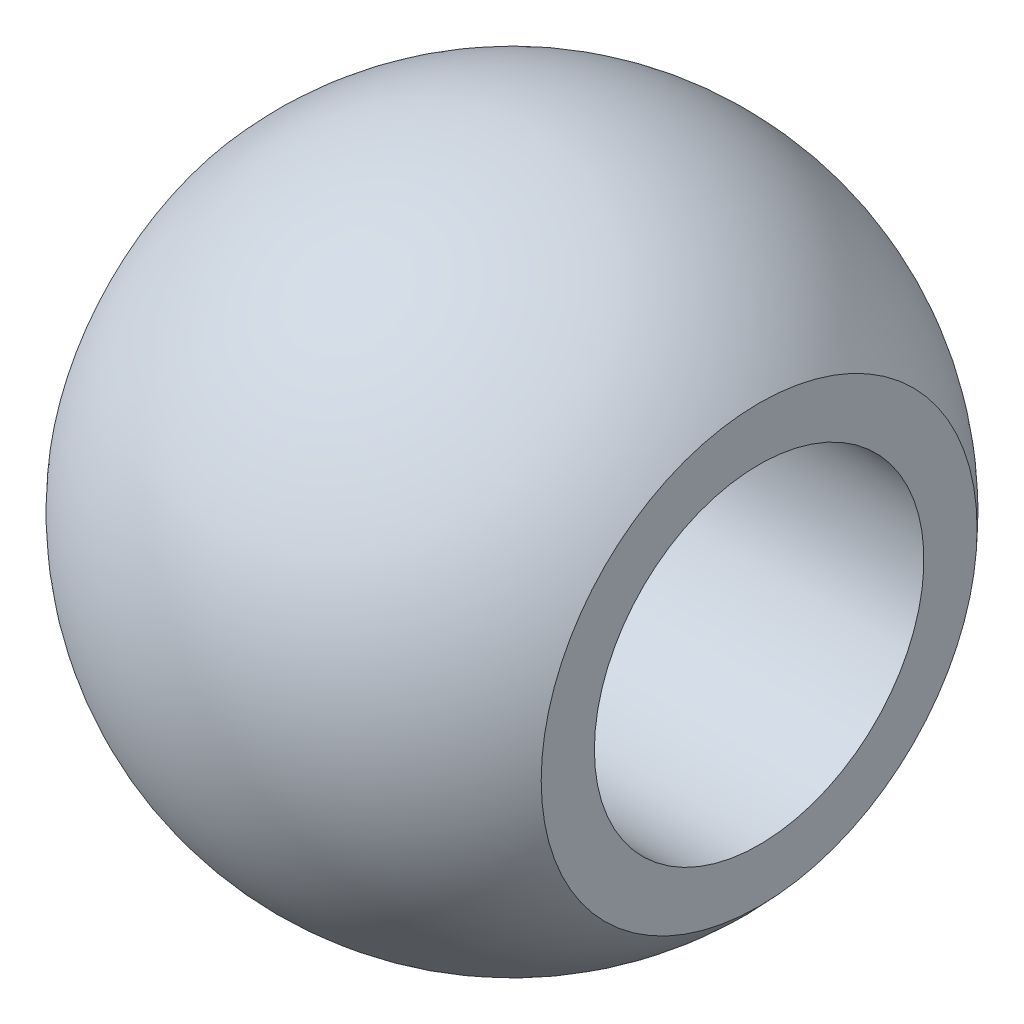
from build123d import *

# Parameters (mm, degrees)
SKETCH2_R               = 5
CUT_EXTRUDE1_DEPTH      = 1
CUT_EXTRUDE1_DEPTH_BACK = 16


with BuildPart() as part:
    # Sketch1 → Revolve1 (revolve)
    with BuildSketch(Plane.XY):
        with BuildLine():
            Line((-7.5, 0), (7.5, 0))
            Line((7.5, 0), (7.5, 6.614378278))
            ThreePointArc((7.5, 6.614378278), (0, 10), (-7.5, 6.614378278))
            Line((-7.5, 6.614378278), (-7.5, 0))
        make_face()
    revolve(axis=Axis((-10, 0, 0), (1, 0, 0)))

    # Sketch2 → Cut-Extrude1 (cut, two sides)
    with BuildSketch(Plane.ZY.offset(7.5)) as cut_extrude1_sk:
        Circle(SKETCH2_R)
    extrude(amount=CUT_EXTRUDE1_DEPTH, mode=Mode.SUBTRACT)
    extrude(cut_extrude1_sk.sketch, amount=-CUT_EXTRUDE1_DEPTH_BACK, mode=Mode.SUBTRACT)


solid = part.part
